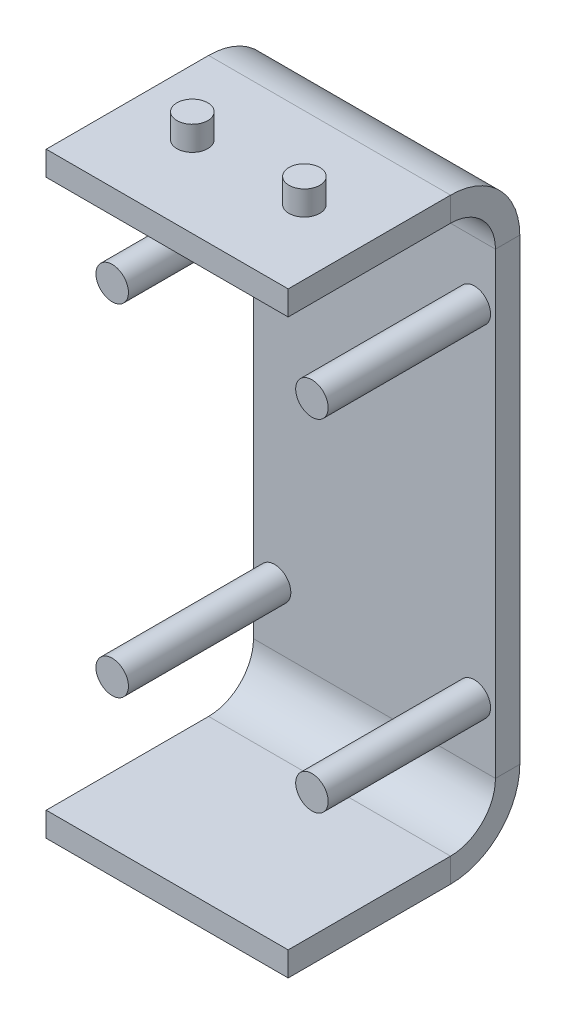
from build123d import *

# Parameters (mm, degrees)
SKETCH_1_W        = 14.9
SKETCH_1_H        = 1.5
EXTRUDE_START     = 0.75
SKETCH_8_R        = 0.95
EXTRUDE_1_DEPTH   = 1.5
EXTRUDE_1_2_DEPTH = 1.5
EXTRUDE_START_2   = -1.5
SKETCH_10_R       = 0.95
EXTRUDE_2_DEPTH   = 1.5
SKETCH_12_R       = 1
EXTRUDE_3_DEPTH   = 10


with BuildPart() as part:
    # 扫描5: sweep along a path in 草图6
    with BuildLine(Plane(origin=(0, 0, 0), x_dir=(0, 0, -1), z_dir=(1, 0, 0))) as sweep_5_path:
        Line((0, 0), (10, 0))
        ThreePointArc((10, 0), (12.484512752, -1.029118878), (13.51363163, -3.51363163))
        Line((13.51363163, -3.51363163), (13.51363163, -31.73636837))
        ThreePointArc((13.51363163, -31.73636837), (12.484512752, -34.220881122), (10, -35.25))
        Line((10, -35.25), (0, -35.25))
    # 草图1 → 扫描5 (sweep)
    with BuildSketch(Plane.XY):
        Rectangle(SKETCH_1_W, SKETCH_1_H)
    sweep(path=sweep_5_path.line)

    # 草图10 → 凸台-拉伸2 (add)
    with BuildSketch(Plane(origin=(0, -34.5, 0), x_dir=(1, 0, 0), z_dir=(0, 1, 0)).offset(EXTRUDE_START_2)):
        with Locations(Location((-3.45, 5, 0), (0, 0, 270))):  # turned: the seam where the file's is
            Circle(SKETCH_10_R)
        with Locations(Location((3.45, 5, 0), (0, 0, 270))):  # turned: the seam where the file's is
            Circle(SKETCH_10_R)
    extrude(amount=-EXTRUDE_2_DEPTH)

    # 草图12 → 凸台-拉伸3 (add)
    with BuildSketch(Plane.XY.offset(-12.76363163)):
        with Locations((-6.15, -28.125)):
            Circle(SKETCH_12_R)
        with Locations((-6.15, -7.125)):
            Circle(SKETCH_12_R)
        with Locations((6.15, -7.125)):
            Circle(SKETCH_12_R)
        with Locations((6.15, -28.125)):
            Circle(SKETCH_12_R)
    extrude(amount=EXTRUDE_3_DEPTH)


with BuildPart() as body_2:
    # 草图8 → 凸台-拉伸1 (new body)
    with BuildSketch(Plane(origin=(0, 0, 0), x_dir=(1, 0, 0), z_dir=(0, 1, 0)).offset(EXTRUDE_START)):
        with Locations(Location((-3.45, 5, 0), (0, 0, 270))):  # turned: the seam where the file's is
            Circle(SKETCH_8_R)
    extrude(amount=EXTRUDE_1_DEPTH)


with BuildPart() as body_3:
    # 草图8 → Extrude 1 2 (new body)
    with BuildSketch(Plane(origin=(0, 0, 0), x_dir=(1, 0, 0), z_dir=(0, 1, 0)).offset(EXTRUDE_START)):
        with Locations(Location((3.45, 5, 0), (0, 0, 270))):  # turned: the seam where the file's is
            Circle(SKETCH_8_R)
    extrude(amount=EXTRUDE_1_2_DEPTH)


solid = Compound([part.part, body_2.part, body_3.part])
